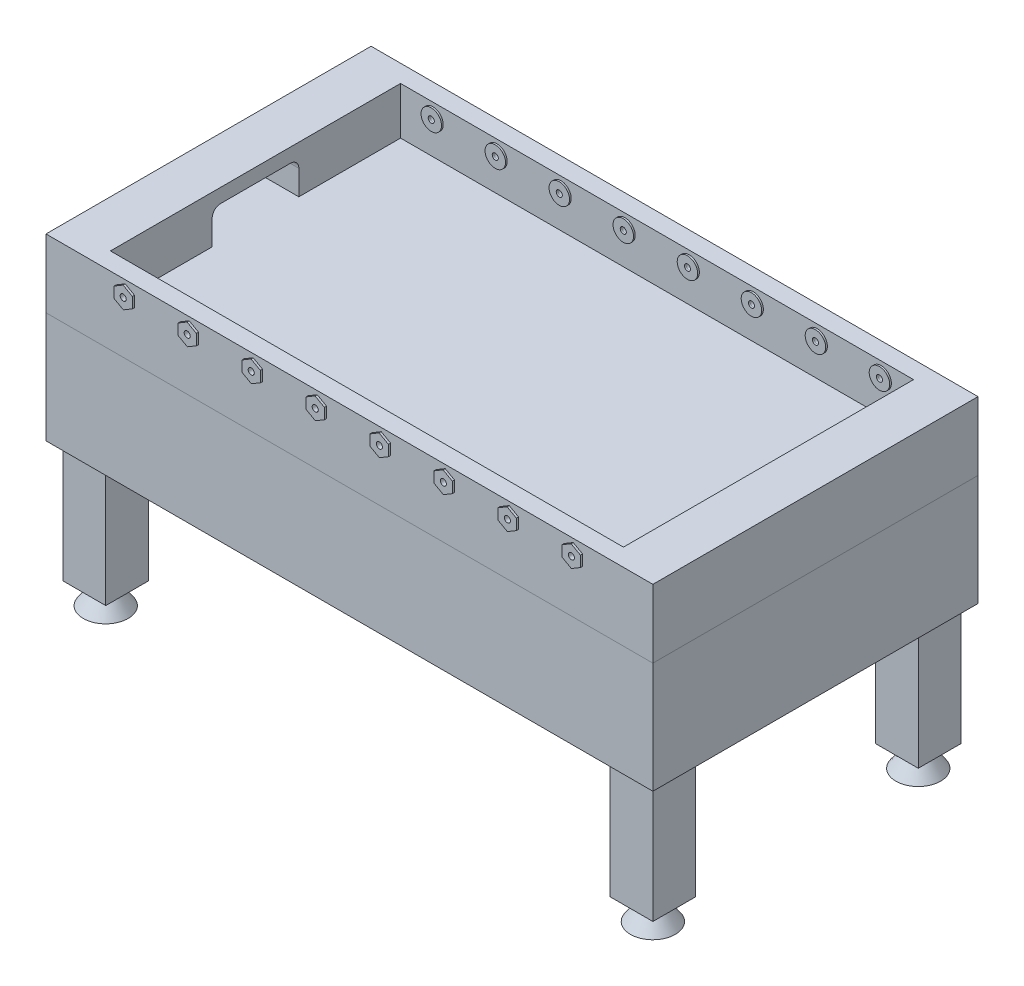
from build123d import *

# Parameters (mm, degrees)
SKETCH_1_W               = 1422.4
SKETCH_1_H               = 762
EXTRUDE_1_DEPTH          = 160
SKETCH_2_W               = 1202.4
SKETCH_2_H               = 680
CUT_EXTRUDE_1_DEPTH      = 111
SKETCH_3_W               = 203.2
SKETCH_3_H               = 78
CUT_EXTRUDE_2_DEPTH      = 80
SKETCH_4_R               = 24
SKETCH_4_R_2             = 7.14375
EXTRUDE_2_DEPTH          = 4
EXTRUDE_2_2_DEPTH        = 4
EXTRUDE_2_3_DEPTH        = 4
EXTRUDE_2_4_DEPTH        = 4
EXTRUDE_2_5_DEPTH        = 4
EXTRUDE_2_6_DEPTH        = 4
EXTRUDE_2_7_DEPTH        = 4
EXTRUDE_2_8_DEPTH        = 4
SKETCH_5_W               = 1422.4
SKETCH_5_H               = 762
EXTRUDE_3_DEPTH          = 260
SKETCH_7_W               = 100
SKETCH_7_H               = 100
EXTRUDE_4_DEPTH          = 284.4
SKETCH_8_R               = 17.5
EXTRUDE_5_DEPTH          = 50
EXTRUDE_5_TAPER          = -35
EXTRUDE_6_DEPTH          = 5
SKETCH_10_R              = 7.14375
CUT_EXTRUDE_4_DEPTH      = 727
CUT_EXTRUDE_4_DEPTH_BACK = 47
SKETCH_11_W              = 162
SKETCH_11_H              = 85
CUT_EXTRUDE_5_DEPTH      = 6
CUT_EXTRUDE_5_DEPTH_BACK = 381
CUT_EXTRUDE_6_DEPTH      = 162
CUT_EXTRUDE_7_DEPTH      = 10
FILLET_1_R               = 20


with BuildPart() as part:
    # 스케치1 → 보스-돌출1 (new body)
    with BuildSketch(Plane(origin=(0, 0, 0), x_dir=(1, 0, 0), z_dir=(0, 1, 0))):
        Rectangle(SKETCH_1_W, SKETCH_1_H)
    extrude(amount=EXTRUDE_1_DEPTH)

    # 스케치2 → 컷-돌출1 (cut)
    with BuildSketch(Plane(origin=(0, 160, 0), x_dir=(1, 0, 0), z_dir=(0, 1, 0))):
        Rectangle(SKETCH_2_W, SKETCH_2_H)
    extrude(amount=-CUT_EXTRUDE_1_DEPTH, mode=Mode.SUBTRACT)

    # 스케치3 → 컷-돌출2 (cut)
    with BuildSketch(Plane.ZY.offset(-601.2)):
        with Locations((0, 88)):
            Rectangle(SKETCH_3_W, SKETCH_3_H)
    cut_extrude_2 = extrude(amount=-CUT_EXTRUDE_2_DEPTH, mode=Mode.SUBTRACT)

    # 대칭 복사1: 컷-돌출2 across plane
    add(cut_extrude_2.mirror(Plane(origin=(0, 0, 0), x_dir=(0, 0, 1), z_dir=(1, 0, 0))), mode=Mode.SUBTRACT)


with BuildPart() as body_2:
    # 스케치4 → 보스-돌출2 (new body)
    with BuildSketch(Plane.XY.offset(-340)):
        with Locations((-525.2, 126.5)):
            Circle(SKETCH_4_R)
        with Locations((-525.2, 126.5)):
            Circle(SKETCH_4_R_2, mode=Mode.SUBTRACT)
    extrude_2 = extrude(amount=EXTRUDE_2_DEPTH)


with BuildPart() as body_3:
    # 스케치4 → Extrude 2 2 (new body)
    with BuildSketch(Plane.XY.offset(-340)):
        with Locations((-375.2, 126.5)):
            Circle(SKETCH_4_R)
        with Locations((-375.2, 126.5)):
            Circle(SKETCH_4_R_2, mode=Mode.SUBTRACT)
    extrude_2_2 = extrude(amount=EXTRUDE_2_2_DEPTH)


with BuildPart() as body_4:
    # 스케치4 → Extrude 2 3 (new body)
    with BuildSketch(Plane.XY.offset(-340)):
        with Locations((-225.2, 126.5)):
            Circle(SKETCH_4_R)
        with Locations((-225.2, 126.5)):
            Circle(SKETCH_4_R_2, mode=Mode.SUBTRACT)
    extrude_2_3 = extrude(amount=EXTRUDE_2_3_DEPTH)


with BuildPart() as body_5:
    # 스케치4 → Extrude 2 4 (new body)
    with BuildSketch(Plane.XY.offset(-340)):
        with Locations((-75.2, 126.5)):
            Circle(SKETCH_4_R)
        with Locations((-75.2, 126.5)):
            Circle(SKETCH_4_R_2, mode=Mode.SUBTRACT)
    extrude_2_4 = extrude(amount=EXTRUDE_2_4_DEPTH)


with BuildPart() as body_6:
    # 스케치4 → Extrude 2 5 (new body)
    with BuildSketch(Plane.XY.offset(-340)):
        with Locations((75.2, 126.5)):
            Circle(SKETCH_4_R)
        with Locations((75.2, 126.5)):
            Circle(SKETCH_4_R_2, mode=Mode.SUBTRACT)
    extrude_2_5 = extrude(amount=EXTRUDE_2_5_DEPTH)


with BuildPart() as body_7:
    # 스케치4 → Extrude 2 6 (new body)
    with BuildSketch(Plane.XY.offset(-340)):
        with Locations((225.2, 126.5)):
            Circle(SKETCH_4_R)
        with Locations((225.2, 126.5)):
            Circle(SKETCH_4_R_2, mode=Mode.SUBTRACT)
    extrude_2_6 = extrude(amount=EXTRUDE_2_6_DEPTH)


with BuildPart() as body_8:
    # 스케치4 → Extrude 2 7 (new body)
    with BuildSketch(Plane.XY.offset(-340)):
        with Locations((375.2, 126.5)):
            Circle(SKETCH_4_R)
        with Locations((375.2, 126.5)):
            Circle(SKETCH_4_R_2, mode=Mode.SUBTRACT)
    extrude_2_7 = extrude(amount=EXTRUDE_2_7_DEPTH)


with BuildPart() as body_9:
    # 스케치4 → Extrude 2 8 (new body)
    with BuildSketch(Plane.XY.offset(-340)):
        with Locations((525.2, 126.5)):
            Circle(SKETCH_4_R)
        with Locations((525.2, 126.5)):
            Circle(SKETCH_4_R_2, mode=Mode.SUBTRACT)
    extrude_2_8 = extrude(amount=EXTRUDE_2_8_DEPTH)


with BuildPart() as part_1:
    add(part.part)

    # 대칭 복사2: 보스-돌출2, Extrude 2 2, Extrude 2 3, Extrude 2 4, Extrude 2 5, Extrude 2 6, Extrude 2 7, Extrude 2 8 across plane
    add(extrude_2.mirror(Plane.XY))
    add(extrude_2_2.mirror(Plane.XY))
    add(extrude_2_3.mirror(Plane.XY))
    add(extrude_2_4.mirror(Plane.XY))
    add(extrude_2_5.mirror(Plane.XY))
    add(extrude_2_6.mirror(Plane.XY))
    add(extrude_2_7.mirror(Plane.XY))
    add(extrude_2_8.mirror(Plane.XY))

    # 스케치9 → 보스-돌출6 (add)
    with BuildSketch(Plane.XY.offset(381)):
        Polygon((-353.375195276, 114.306645304), (-353.727842714, 139.304157976), (-375.552647438, 151.497512672), (-397.024804724, 138.693354696), (-396.672157286, 113.695842024), (-374.847352562, 101.502487328), align=None)
        Polygon((-503.375195276, 114.306645304), (-503.727842714, 139.304157976), (-525.552647438, 151.497512672), (-547.024804724, 138.693354696), (-546.672157286, 113.695842024), (-524.847352562, 101.502487328), align=None)
        Polygon((-203.375195276, 114.306645304), (-203.727842714, 139.304157976), (-225.552647438, 151.497512672), (-247.024804724, 138.693354696), (-246.672157286, 113.695842024), (-224.847352562, 101.502487328), align=None)
        Polygon((-53.375195276, 114.306645304), (-53.727842714, 139.304157976), (-75.552647438, 151.497512672), (-97.024804724, 138.693354696), (-96.672157286, 113.695842024), (-74.847352562, 101.502487328), align=None)
        Polygon((96.624804724, 114.306645304), (96.272157286, 139.304157976), (74.447352562, 151.497512672), (52.975195276, 138.693354696), (53.327842714, 113.695842024), (75.152647438, 101.502487328), align=None)
        Polygon((246.624804724, 114.306645304), (246.272157286, 139.304157976), (224.447352562, 151.497512672), (202.975195276, 138.693354696), (203.327842714, 113.695842024), (225.152647438, 101.502487328), align=None)
        Polygon((396.624804724, 114.306645304), (396.272157286, 139.304157976), (374.447352562, 151.497512672), (352.975195276, 138.693354696), (353.327842714, 113.695842024), (375.152647438, 101.502487328), align=None)
        Polygon((546.624804724, 114.306645304), (546.272157286, 139.304157976), (524.447352562, 151.497512672), (502.975195276, 138.693354696), (503.327842714, 113.695842024), (525.152647438, 101.502487328), align=None)
    extrude_6 = extrude(amount=EXTRUDE_6_DEPTH)

    # 대칭 복사3: 보스-돌출6 across plane
    add(extrude_6.mirror(Plane.XY))

    # 스케치10 → 컷-돌출4 (cut, two sides)
    with BuildSketch(Plane.XY.offset(-340)) as cut_extrude_4_sk:
        with Locations((525.2, 126.5)):
            Circle(SKETCH_10_R)
        with Locations((375.2, 126.5)):
            Circle(SKETCH_10_R)
        with Locations((225.2, 126.5)):
            Circle(SKETCH_10_R)
        with Locations((75.2, 126.5)):
            Circle(SKETCH_10_R)
        with Locations((-75.2, 126.5)):
            Circle(SKETCH_10_R)
        with Locations((-225.2, 126.5)):
            Circle(SKETCH_10_R)
        with Locations((-375.2, 126.5)):
            Circle(SKETCH_10_R)
        with Locations((-525.2, 126.5)):
            Circle(SKETCH_10_R)
    extrude(amount=CUT_EXTRUDE_4_DEPTH, mode=Mode.SUBTRACT)
    extrude(cut_extrude_4_sk.sketch, amount=-CUT_EXTRUDE_4_DEPTH_BACK, mode=Mode.SUBTRACT)

    # 필렛1
    fillet_1_edges = [part_1.edges().sort_by_distance(p)[0] for p in [
        (641.2, 127, 101.6),
        (641.2, 127, -101.6),
        (-641.2, 127, 101.6),
        (-641.2, 127, -101.6),
    ]]
    fillet(fillet_1_edges, radius=FILLET_1_R)


with BuildPart() as body_10:
    # 스케치5 → 보스-돌출3 (new body)
    with BuildSketch(Plane.XZ):
        Rectangle(SKETCH_5_W, SKETCH_5_H)
    extrude(amount=EXTRUDE_3_DEPTH)

    # 스케치7 → 보스-돌출4 (add)
    with BuildSketch(Plane.XZ.offset(260)):
        with Locations((-641.2, 311)):
            Rectangle(SKETCH_7_W, SKETCH_7_H)
        with Locations((641.2, 311)):
            Rectangle(SKETCH_7_W, SKETCH_7_H)
        with Locations((641.2, -311)):
            Rectangle(SKETCH_7_W, SKETCH_7_H)
        with Locations((-641.2, -311)):
            Rectangle(SKETCH_7_W, SKETCH_7_H)
    extrude(amount=EXTRUDE_4_DEPTH)

    # 스케치8 → 보스-돌출5 (add)
    with BuildSketch(Plane.XZ.offset(544.4)):
        with Locations((-641.2, 311)):
            Circle(SKETCH_8_R)
        with Locations((641.2, 311)):
            Circle(SKETCH_8_R)
        with Locations((641.2, -311)):
            Circle(SKETCH_8_R)
        with Locations((-641.2, -311)):
            Circle(SKETCH_8_R)
    extrude(amount=EXTRUDE_5_DEPTH, taper=EXTRUDE_5_TAPER)

    # 스케치11 → 컷-돌출5 (cut, two sides)
    with BuildSketch(Plane(origin=(0, 0, -381), x_dir=(-1, 0, 0), z_dir=(0, 0, -1))) as cut_extrude_5_sk:
        with Locations((0, -42.5)):
            Rectangle(SKETCH_11_W, SKETCH_11_H)
    extrude(amount=CUT_EXTRUDE_5_DEPTH, mode=Mode.SUBTRACT)
    extrude(cut_extrude_5_sk.sketch, amount=-CUT_EXTRUDE_5_DEPTH_BACK, mode=Mode.SUBTRACT)

    # 스케치14 → 컷-돌출6 (cut)
    with BuildSketch(Plane(origin=(-81, 0, 0), x_dir=(0, 0, -1), z_dir=(1, 0, 0))):
        Polygon((0, -85), (361, -108.114), (361, -85), align=None)
    extrude(amount=CUT_EXTRUDE_6_DEPTH, mode=Mode.SUBTRACT)

    # 스케치15 → 컷-돌출7 (cut)
    with BuildSketch(Plane.ZY.offset(-81)):
        Polygon((-361, 0), (-361, -108.114), (0, -85), (0, 0), align=None)
    cut_extrude_7 = extrude(amount=-CUT_EXTRUDE_7_DEPTH, mode=Mode.SUBTRACT)

    # 대칭 복사4: 컷-돌출7 across plane
    add(cut_extrude_7.mirror(Plane(origin=(0, 0, 0), x_dir=(0, 0, 1), z_dir=(1, 0, 0))), mode=Mode.SUBTRACT)


solid = Compound([body_2.part, body_3.part, body_4.part, body_5.part, body_6.part, body_7.part, body_8.part, body_9.part, part_1.part, body_10.part])
